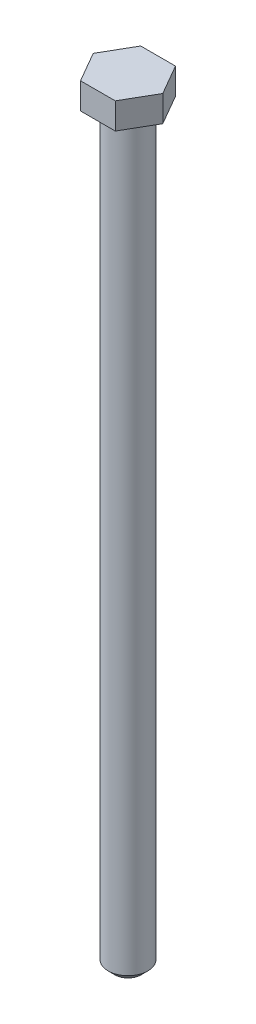
from build123d import *

# Parameters (mm, degrees)
EXTRUDE1_DEPTH = 6.223
SKETCH2_R      = 4.699
EXTRUDE2_DEPTH = 177.8
CHAMFER1_SIZE  = 1.5875


with BuildPart() as part:
    # Sketch1 → Extrude1 (new body)
    with BuildSketch(Plane(origin=(0, 0, 0), x_dir=(1, 0, 0), z_dir=(0, 1, 0))):
        Polygon((8.263556668, 0), (4.131778334, 7.15645), (-4.131778334, 7.15645), (-8.263556668, 0), (-4.131778334, -7.15645), (4.131778334, -7.15645), align=None)
    extrude(amount=-EXTRUDE1_DEPTH)

    # Sketch2 → Extrude2 (add)
    with BuildSketch(Plane.XZ.offset(6.223)):
        Circle(SKETCH2_R)
    extrude(amount=EXTRUDE2_DEPTH)

    # Chamfer1
    chamfer1_edges = [part.edges().sort_by_distance(p)[0] for p in [
        (-4.699, -184.023, 0),
    ]]
    chamfer(chamfer1_edges, length=CHAMFER1_SIZE)


solid = part.part
